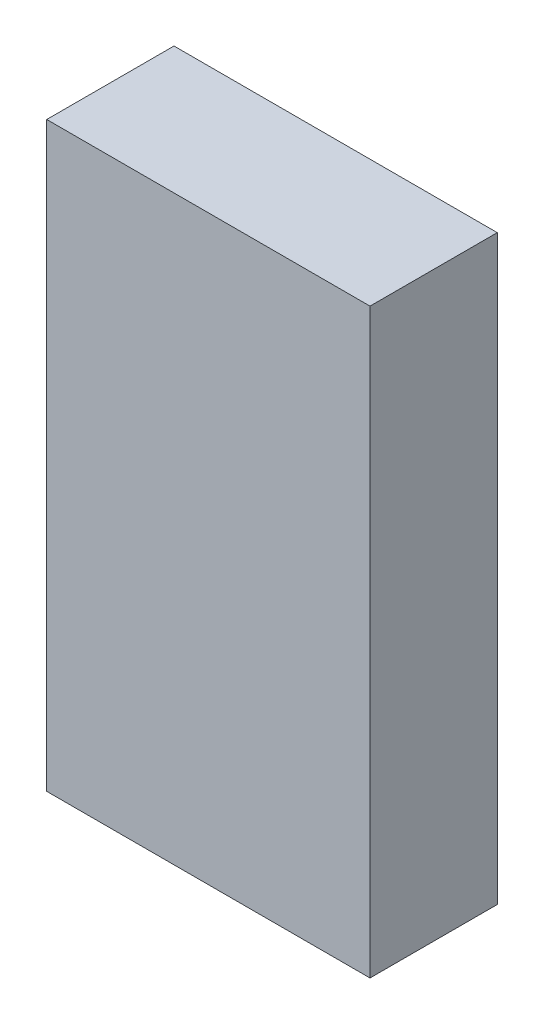
from build123d import *

# Parameters (mm, degrees)
SKETCH1_W               = 2.54
SKETCH1_H               = 4.572
COMPONENT_OUTLINE_DEPTH = 1


with BuildPart() as part:
    # Sketch1 → Component_Outline (new body)
    with BuildSketch(Plane.XY):
        Rectangle(SKETCH1_W, SKETCH1_H)
    extrude(amount=COMPONENT_OUTLINE_DEPTH)


solid = part.part
